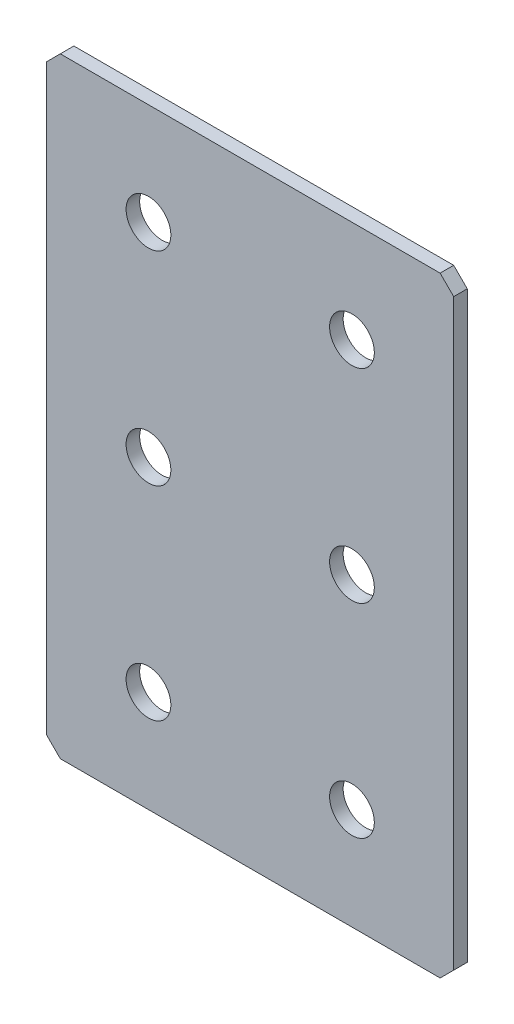
from build123d import *

# Parameters (mm, degrees)
SKETCH_1_W        = 60
SKETCH_1_H        = 90
EXTRUDE_1_DEPTH   = 2
CHAMFER_1_SIZE    = 2
HOLE_WIZARD_M61_D = 6.6


with BuildPart() as part:
    # Эскиз1 → Бобышка-Вытянуть1 (new body)
    with BuildSketch(Plane.XY):
        Rectangle(SKETCH_1_W, SKETCH_1_H)
    extrude(amount=EXTRUDE_1_DEPTH)

    # Фаска1
    chamfer_1_edges = [part.edges().sort_by_distance(p)[0] for p in [
        (30, -45, 1),
        (-30, -45, 1),
        (-30, 45, 1),
        (30, 45, 1),
    ]]
    chamfer(chamfer_1_edges, length=CHAMFER_1_SIZE)

    # Отверстие с зазором M61 (through all)
    with Locations(Plane.XY.offset(2)):
        with Locations((-15, 30), (15, 30), (15, 0), (-15, 0), (-15, -30), (15, -30)):
            Hole(HOLE_WIZARD_M61_D / 2)


solid = part.part
